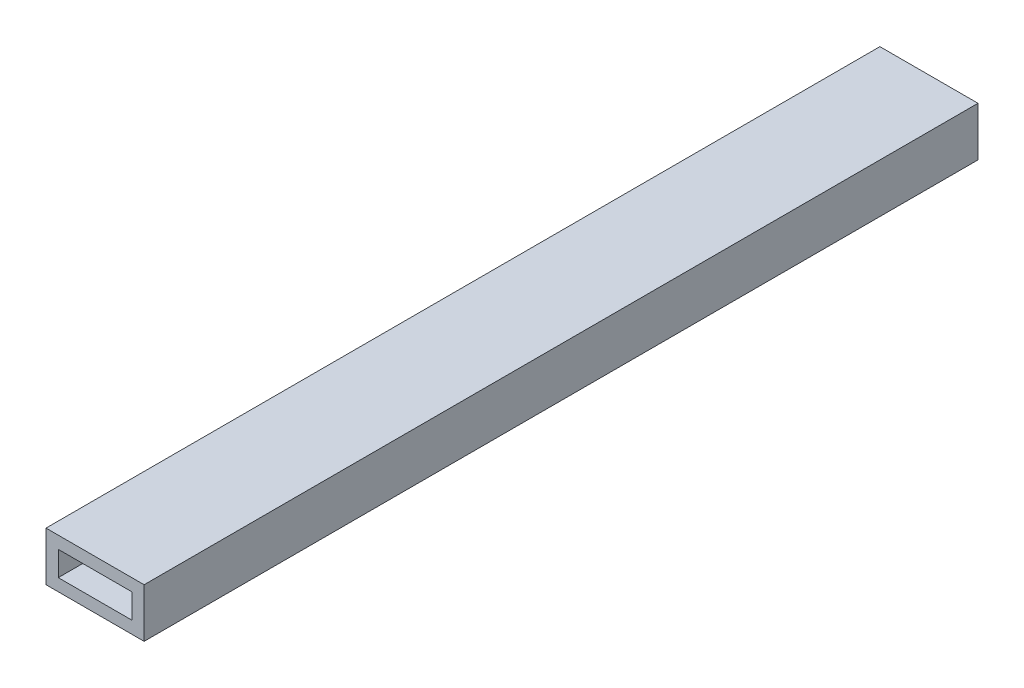
from build123d import *

# Parameters (mm, degrees)
SKETCH1_W           = 25.4
SKETCH1_H           = 12.7
BOSS_EXTRUDE1_DEPTH = 215.9
SKETCH3_W           = 19.05
SKETCH3_H           = 6.35
CUT_EXTRUDE1_DEPTH  = 216.9


with BuildPart() as part:
    # Sketch1 → Boss-Extrude1 (new body)
    with BuildSketch(Plane.XY):
        with Locations((2.2752443, 1.716775244)):
            Rectangle(SKETCH1_W, SKETCH1_H)
    extrude(amount=BOSS_EXTRUDE1_DEPTH)

    # Sketch3 → Cut-Extrude1 (cut, through all)
    with BuildSketch(Plane(origin=(0, 0, 0), x_dir=(-1, 0, 0), z_dir=(0, 0, -1))):
        with Locations((-2.2752443, 1.716775244)):
            Rectangle(SKETCH3_W, SKETCH3_H)
    extrude(amount=-CUT_EXTRUDE1_DEPTH, mode=Mode.SUBTRACT)


solid = part.part
